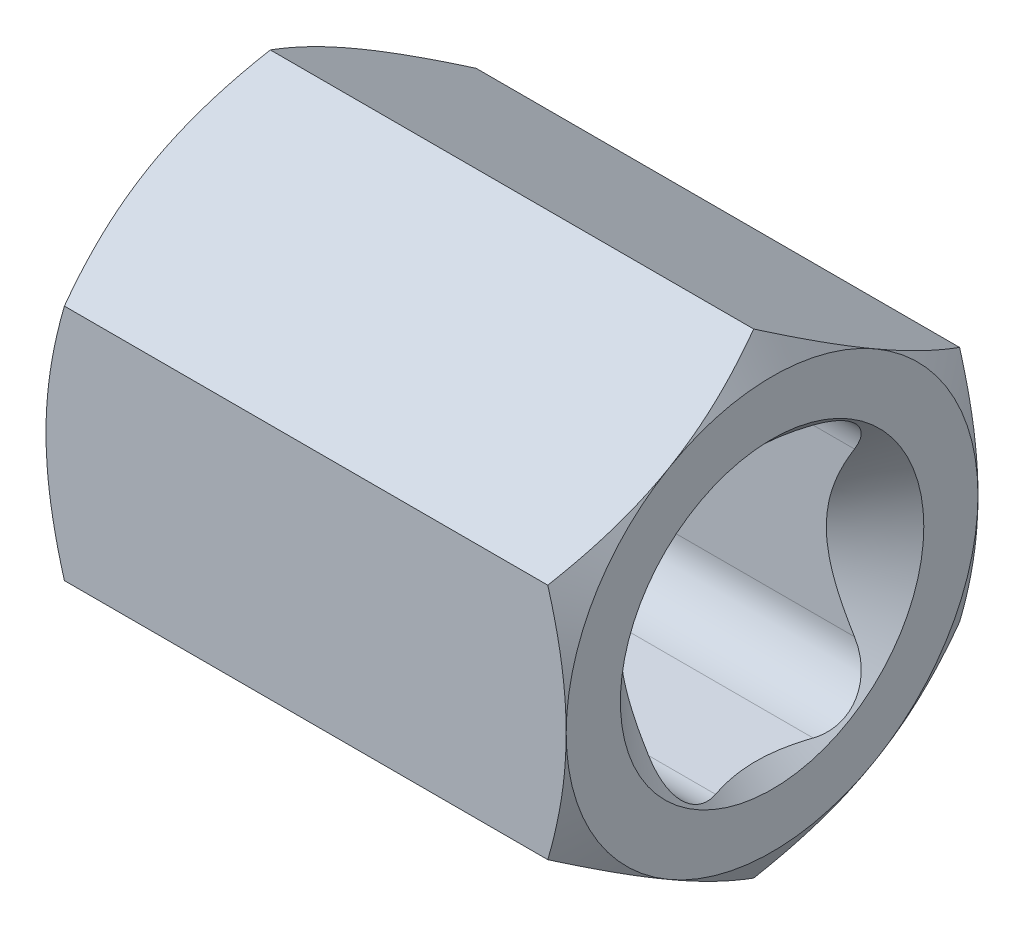
from build123d import *

# Parameters (mm, degrees)
BOSS_EXTRU_1_DEPTH = 24


with BuildPart() as part:
    # Esquisse1 → Boss.-Extru.1 (new body)
    with BuildSketch(Plane(origin=(0, 0, 0), x_dir=(0, 0, -1), z_dir=(1, 0, 0))):
        Polygon((-9.5, -5.484827557), (-9.5, 5.484827557), (0, 10.969655115), (9.5, 5.484827557), (9.5, -5.484827557), (0, -10.969655115), align=None)
        with BuildLine():
            Line((2.25, 6.25), (-2.25, 6.25))
            ThreePointArc((-2.25, 6.25), (-4.017766953, 5.517766953), (-4.75, 3.75))
            Line((-4.75, 3.75), (-4.75, -3.75))
            ThreePointArc((-4.75, -3.75), (-4.017766953, -5.517766953), (-2.25, -6.25))
            Line((-2.25, -6.25), (2.25, -6.25))
            ThreePointArc((2.25, -6.25), (4.017766953, -5.517766953), (4.75, -3.75))
            Line((4.75, -3.75), (4.75, 3.75))
            ThreePointArc((4.75, 3.75), (4.017766953, 5.517766953), (2.25, 6.25))
        make_face(mode=Mode.SUBTRACT)
    extrude(amount=BOSS_EXTRU_1_DEPTH)

    # Esquisse6 → Enlèvement de matière-Révolution1 (revolve, cut)
    with BuildSketch(Plane(origin=(0, 0, 0), x_dir=(1, 0, 0), z_dir=(0, 1, 0))):
        Polygon((-4.48433242, 1.732908411), (2.760156758, 14.280731742), (21.239843242, 14.280731742), (28.008759285, 2.556625243), (28.008759285, 15.540866197), (-4.48433242, 15.540866197), align=None)
    revolve(axis=Axis((24, 0, 0), (-1, 0, 0)), mode=Mode.SUBTRACT)

    # Esquisse11 → Enlèvement de matière-Révolution3 (revolve, cut)
    with BuildSketch(Plane(origin=(0, 0, 0), x_dir=(1, 0, 0), z_dir=(0, 1, 0)), mode=Mode.PRIVATE) as enl_vement_de_mati_re_r_volution3_sk:
        Polygon((0, 0), (0, -7), (3, -4), (21, -4), (24, -7), (24, 0), align=None)
    revolve(enl_vement_de_mati_re_r_volution3_sk.sketch.rotate(Axis((24, 0, 0), (-1, 0, 0)), 180), axis=Axis((24, 0, 0), (-1, 0, 0)), mode=Mode.SUBTRACT)  # turned: the seam where the file's is


solid = part.part
